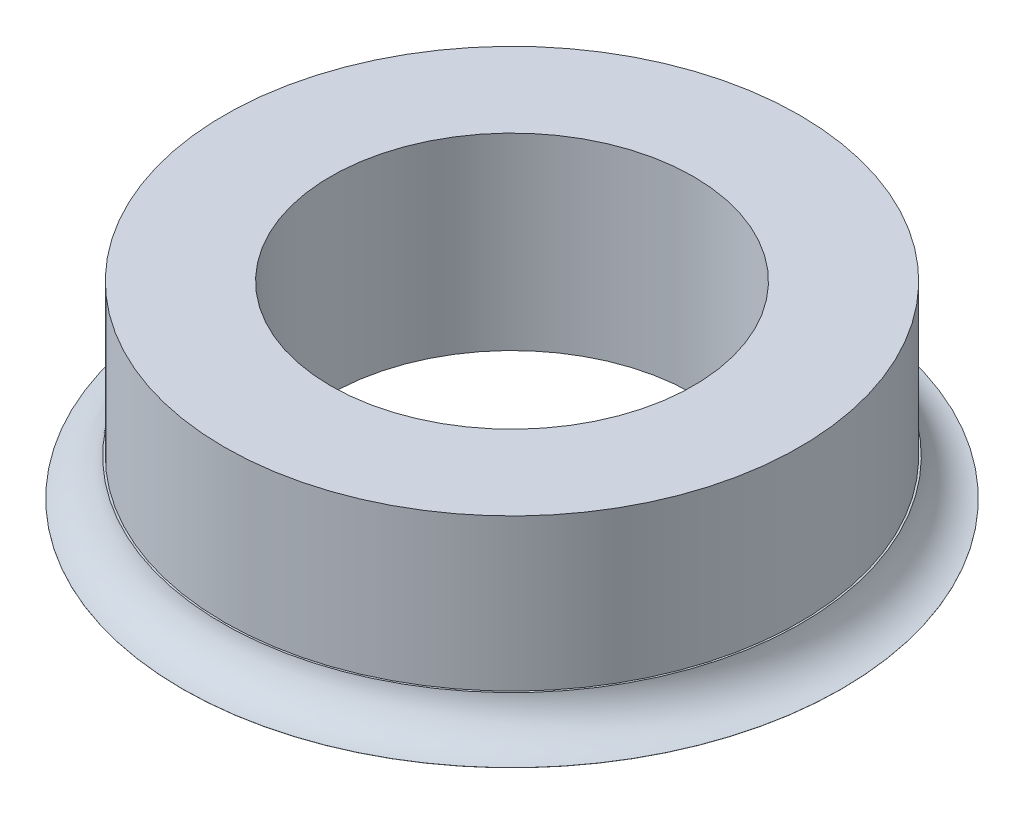
from build123d import *

# Parameters (mm, degrees)
SKETCH_1_R      = 3.925
SKETCH_1_R_2    = 2.475
EXTRUDE_1_DEPTH = 2.57
SKETCH_2_R      = 4.5
SKETCH_2_R_2    = 3.925
EXTRUDE_2_DEPTH = 0.5


with BuildPart() as part:
    # Эскиз1 → Бобышка-Вытянуть1 (new body)
    with BuildSketch(Plane(origin=(0, 0, 0), x_dir=(1, 0, 0), z_dir=(0, 1, 0))):
        Circle(SKETCH_1_R)
        Circle(SKETCH_1_R_2, mode=Mode.SUBTRACT)
    extrude(amount=EXTRUDE_1_DEPTH)

    # Эскиз2 → Бобышка-Вытянуть2 (add)
    with BuildSketch(Plane.XZ):
        Circle(SKETCH_2_R)
        Circle(SKETCH_2_R_2, mode=Mode.SUBTRACT)
    extrude(amount=-EXTRUDE_2_DEPTH)

    # Эскиз3 → Вырез-Повернуть1 (revolve, cut)
    with BuildSketch(Plane.XY):
        with BuildLine():
            Line((-4.5, 0.001444425), (-4.5, 0.5))
            Line((-4.5, 0.5), (-3.95, 0.5))
            ThreePointArc((-3.95, 0.5), (-4.138643926, 0.15545532), (-4.5, 0.001444425))
        make_face()
    revolve(axis=Axis((0, 0, 0), (0, 1, 0)), mode=Mode.SUBTRACT)


solid = part.part
